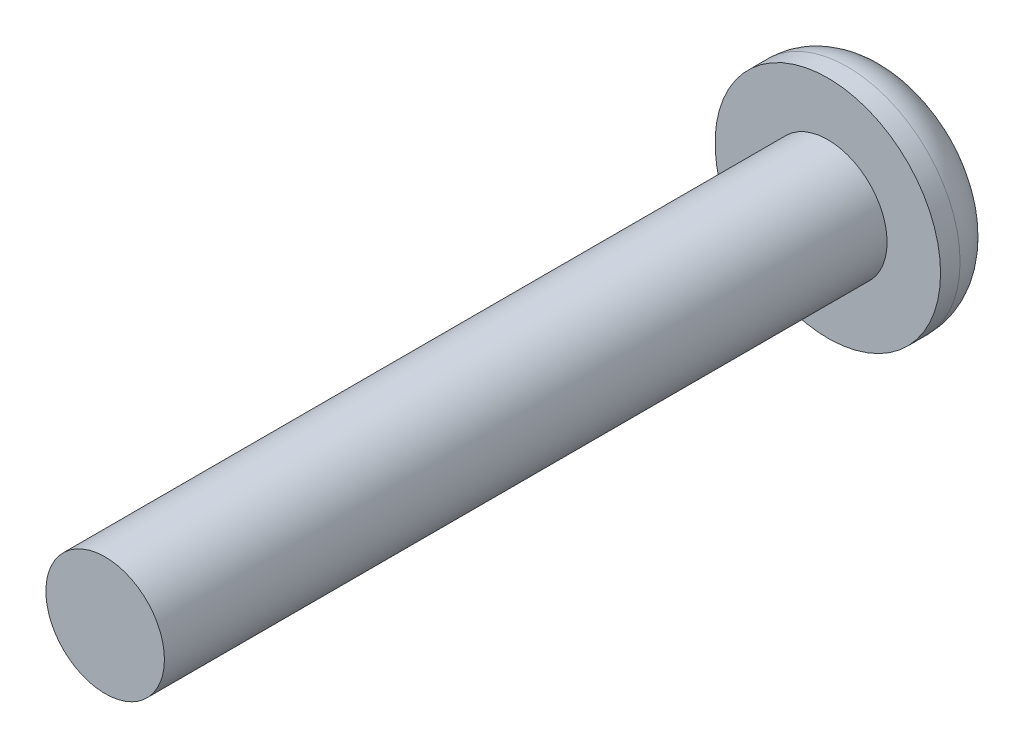
from build123d import *

# Parameters (mm, degrees)
SKETCH1_R      = 3.9624
EXTRUDE1_DEPTH = 2.2098
FILLET1_R      = 1.524
SKETCH2_R      = 2.0828
EXTRUDE2_DEPTH = 25.4
EXTRUDE3_DEPTH = 1.016


with BuildPart() as part:
    # Sketch1 → Extrude1 (new body)
    with BuildSketch(Plane.XY):
        Circle(SKETCH1_R)
    extrude(amount=EXTRUDE1_DEPTH)

    # Fillet1
    fillet1_edges = [part.edges().sort_by_distance(p)[0] for p in [
        (-3.9624, 0, 0),
    ]]
    fillet(fillet1_edges, radius=FILLET1_R)

    # Sketch2 → Extrude2 (add)
    with BuildSketch(Plane.XY.offset(2.2098)):
        Circle(SKETCH2_R)
    extrude(amount=EXTRUDE2_DEPTH)

    # Sketch3 → Extrude3 (cut)
    with BuildSketch(Plane(origin=(0, 0, 0), x_dir=(-1, 0, 0), z_dir=(0, 0, -1))):
        Polygon((0.709024608, 1.177879999), (-0.665561698, 1.202973322), (-1.374586306, 0.025093323), (-0.709024608, -1.177879999), (0.665561698, -1.202973322), (1.374586306, -0.025093323), align=None)
    extrude(amount=-EXTRUDE3_DEPTH, mode=Mode.SUBTRACT)


solid = part.part
